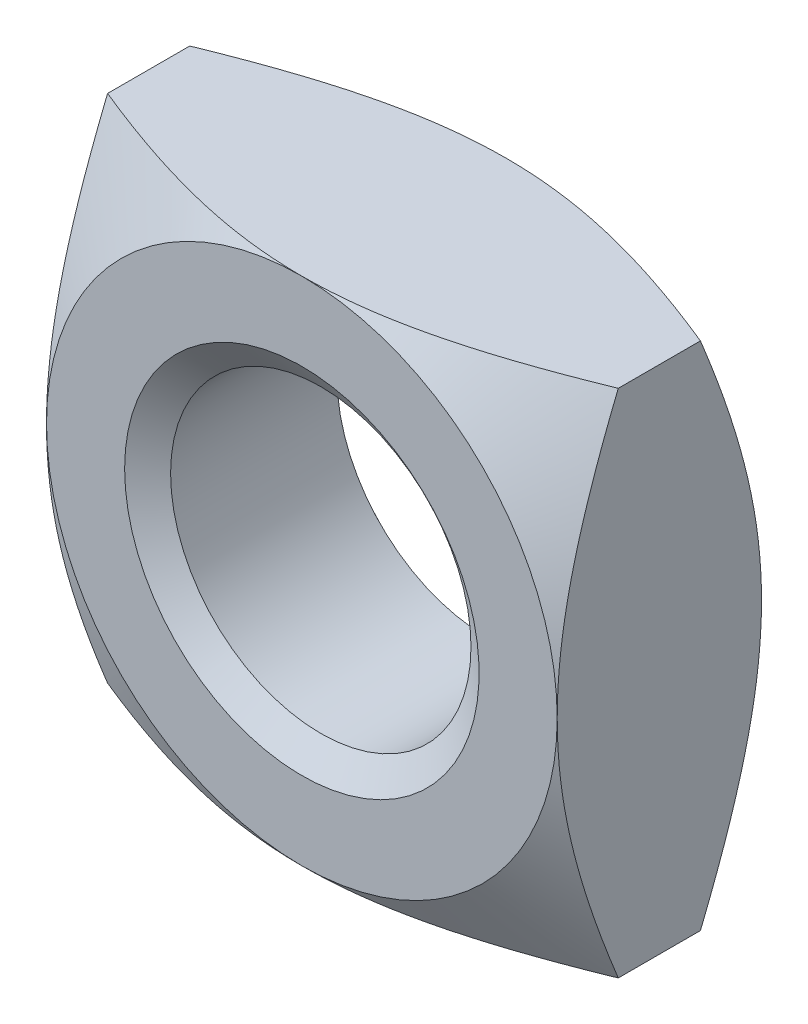
from build123d import *

# Parameters (mm, degrees)
SKETCH2_OUTSIDE_W   = 14.88
SKETCH2_OUTSIDE_H   = 14.88
SKETCH2_OUTSIDE_W_2 = 6.8
SKETCH2_OUTSIDE_H_2 = 6.8
CUT_EXTRUDE1_DEPTH  = 1.36


with BuildPart() as part:
    # Sketch1 → Revolve1 (revolve)
    with BuildSketch(Plane(origin=(0, 0, 0), x_dir=(0, 0, -1), z_dir=(1, 0, 0))):
        Polygon((0.436239569, 5), (-0.436239569, 5), (-1.36, 3.4), (-1.36, 2.36), (-1.107925286, 2), (1.107925286, 2), (1.36, 2.36), (1.36, 3.4), align=None)
    revolve(axis=Axis((0, 0, -2), (0, 0, 1)))

    # Sketch2 outside → Cut-Extrude1 (cut, symmetric)
    with BuildSketch(Plane.XY):
        Rectangle(SKETCH2_OUTSIDE_W, SKETCH2_OUTSIDE_H)
        Rectangle(SKETCH2_OUTSIDE_W_2, SKETCH2_OUTSIDE_H_2, mode=Mode.SUBTRACT)
    extrude(amount=CUT_EXTRUDE1_DEPTH, both=True, mode=Mode.SUBTRACT)


solid = part.part
